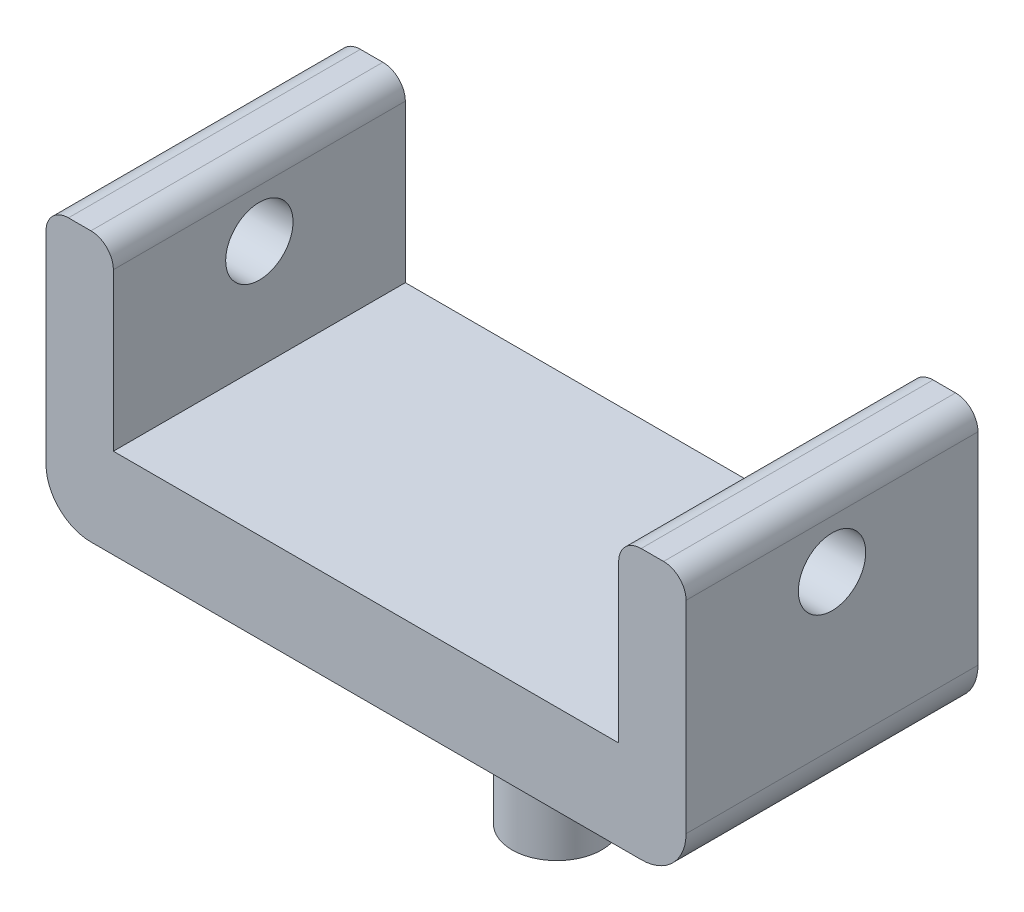
from build123d import *

# Parameters (mm, degrees)
SKETCH1_W           = 28.5
SKETCH1_H           = 17
BOSS_EXTRUDE1_DEPTH = 4
SKETCH2_W           = 3
SKETCH2_H           = 17
BOSS_EXTRUDE2_DEPTH = 8
SKETCH3_R           = 1.5
CUT_EXTRUDE1_DEPTH  = 29.5
SKETCH4_R           = 2
BOSS_EXTRUDE3_DEPTH = 9
FILLET1_R           = 2
FILLET2_R           = 2
FILLET3_R           = 1
SKETCH5_W           = 36.717008867
SKETCH5_H           = 6.82374105
CUT_EXTRUDE2_DEPTH  = 12


with BuildPart() as part:
    # Sketch1 → Boss-Extrude1 (new body)
    with BuildSketch(Plane(origin=(0, 0, 0), x_dir=(1, 0, 0), z_dir=(0, 1, 0))):
        with Locations((1.602817149, -3.658837531)):
            Rectangle(SKETCH1_W, SKETCH1_H)
    extrude(amount=BOSS_EXTRUDE1_DEPTH)

    # Sketch2 → Boss-Extrude2 (add)
    with BuildSketch(Plane(origin=(0, 4, 0), x_dir=(1, 0, 0), z_dir=(0, 1, 0))):
        with Locations((-11.147182851, -3.658837531)):
            Rectangle(SKETCH2_W, SKETCH2_H)
        with Locations((14.352817149, -3.658837531)):
            Rectangle(SKETCH2_W, SKETCH2_H)
    extrude(amount=BOSS_EXTRUDE2_DEPTH)

    # Sketch3 → Cut-Extrude1 (cut, through all)
    with BuildSketch(Plane.ZY.offset(12.647182851)):
        with Locations((5.658837531, 8.85)):
            Circle(SKETCH3_R)
    extrude(amount=-CUT_EXTRUDE1_DEPTH, mode=Mode.SUBTRACT)

    # Sketch4 → Boss-Extrude3 (add)
    with BuildSketch(Plane.XZ):
        with Locations((1.602817149, 3.658837531)):
            Circle(SKETCH4_R)
    extrude(amount=BOSS_EXTRUDE3_DEPTH)

    # Fillet1
    fillet1_edges = [part.edges().sort_by_distance(p)[0] for p in [
        (-0.397182851, 0, 3.658837531),
    ]]
    fillet(fillet1_edges, radius=FILLET1_R)

    # Fillet2
    fillet2_edges = [part.edges().sort_by_distance(p)[0] for p in [
        (15.852817149, 0, 3.658837531),
        (-12.647182851, 0, 3.658837531),
    ]]
    fillet(fillet2_edges, radius=FILLET2_R)

    # Fillet3
    fillet3_edges = [part.edges().sort_by_distance(p)[0] for p in [
        (-12.647182851, 12, 3.658837531),
        (-9.647182851, 12, 3.658837531),
        (15.852817149, 12, 3.658837531),
        (12.852817149, 12, 3.658837531),
    ]]
    fillet(fillet3_edges, radius=FILLET3_R)

    # Sketch5 → Cut-Extrude2 (cut)
    with BuildSketch(Plane.XZ):
        with Locations((1.100738545, -4.253032994)):
            Rectangle(SKETCH5_W, SKETCH5_H)
    extrude(amount=-CUT_EXTRUDE2_DEPTH, mode=Mode.SUBTRACT)


solid = part.part
